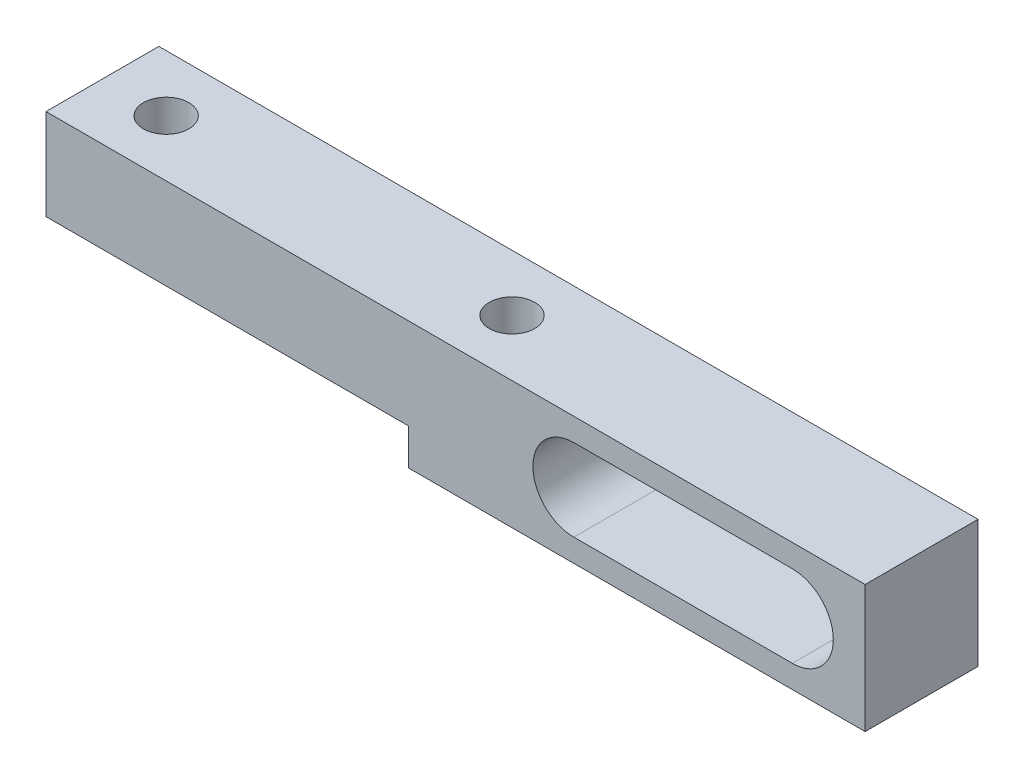
from build123d import *

# Parameters (mm, degrees)
EXTRUDE_2_DEPTH    = 6.2
HOLE_WIZARD_M3_1_D = 2.5


with BuildPart() as part:
    # 草图1 → 凸台-拉伸2 (new body)
    with BuildSketch(Plane.XY):
        Polygon((45, 5), (0, 5), (0, 0), (19.924787558, 0), (19.924787558, -2), (45, -2), align=None)
        with BuildLine():
            Line((29, -0.75), (41, -0.75))
            ThreePointArc((41, -0.75), (43.25, 1.5), (41, 3.75))
            Line((41, 3.75), (29, 3.75))
            ThreePointArc((29, 3.75), (26.75, 1.5), (29, -0.75))
        make_face(mode=Mode.SUBTRACT)
    extrude(amount=EXTRUDE_2_DEPTH)

    # M3 螺纹孔1 (through all)
    with Locations(Plane(origin=(0, -2, 0), x_dir=(-1, 0, 0), z_dir=(0, -1, 0))):
        with Locations((-22.5, -3.1), (-3.5, -3.1)):
            Hole(HOLE_WIZARD_M3_1_D / 2)


solid = part.part
